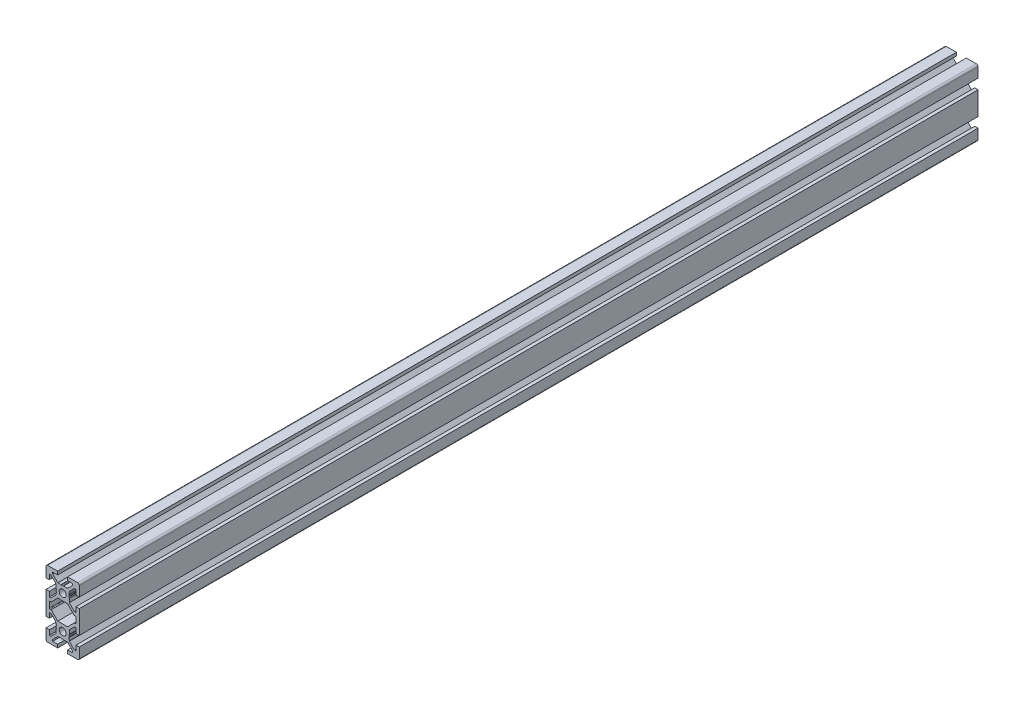
from build123d import *

# Parameters (mm, degrees)
SKETCH1_R           = 2.1
BOSS_EXTRUDE1_DEPTH = 540
SKETCH2_R           = 2
CUT_EXTRUDE1_DEPTH  = 21


with BuildPart() as part:
    # Sketch1 → Boss-Extrude1 (new body)
    with BuildSketch(Plane(origin=(0, 0, -600), x_dir=(-1, 0, 0), z_dir=(0, 0, -1))):
        with BuildLine():
            Line((10, -7), (10, 7))
            Line((10, 7), (8, 7))
            Line((8, 7), (8, 4))
            Line((8, 4), (7.060660172, 4))
            Line((7.060660172, 4), (4, 7.060660172))
            Line((4, 7.060660172), (4, 7.5))
            Line((4, 7.5), (3.750976592, 8.781114371))
            Line((3.750976592, 8.781114371), (3.933012702, 9.096410162))
            ThreePointArc((3.933012702, 9.096410162), (4, 9.346410162), (3.933012702, 9.596410162))
            Line((3.933012702, 9.596410162), (3.7, 10))
            Line((3.7, 10), (3.933012702, 10.403589838))
            ThreePointArc((3.933012702, 10.403589838), (3.982962913, 10.524180316), (4, 10.653589838))
            Line((4, 10.653589838), (4, 12.939339828))
            Line((4, 12.939339828), (7.060660172, 16))
            Line((7.060660172, 16), (8, 16))
            Line((8, 16), (8, 13))
            Line((8, 13), (10, 13))
            Line((10, 13), (10, 19))
            ThreePointArc((10, 19), (9.707106781, 19.707106781), (9, 20))
            Line((9, 20), (3, 20))
            Line((3, 20), (3, 18))
            Line((3, 18), (6, 18))
            Line((6, 18), (6, 17.060660172))
            Line((6, 17.060660172), (2.939339828, 14))
            Line((2.939339828, 14), (2.5, 14))
            Line((2.5, 14), (1.218885629, 13.750976592))
            Line((1.218885629, 13.750976592), (0.903589838, 13.933012702))
            ThreePointArc((0.903589838, 13.933012702), (0.653589838, 14), (0.403589838, 13.933012702))
            Line((0.403589838, 13.933012702), (0, 13.7))
            Line((0, 13.7), (-0.403589838, 13.933012702))
            ThreePointArc((-0.403589838, 13.933012702), (-0.524180316, 13.982962913), (-0.653589838, 14))
            Line((-0.653589838, 14), (-2.939339828, 14))
            Line((-2.939339828, 14), (-6, 17.060660172))
            Line((-6, 17.060660172), (-6, 18))
            Line((-6, 18), (-3, 18))
            Line((-3, 18), (-3, 20))
            Line((-3, 20), (-9, 20))
            ThreePointArc((-9, 20), (-9.707106781, 19.707106781), (-10, 19))
            Line((-10, 19), (-10, 13))
            Line((-10, 13), (-8, 13))
            Line((-8, 13), (-8, 16))
            Line((-8, 16), (-7.060660172, 16))
            Line((-7.060660172, 16), (-4, 12.939339828))
            Line((-4, 12.939339828), (-4, 12.5))
            Line((-4, 12.5), (-3.750976592, 11.218885629))
            Line((-3.750976592, 11.218885629), (-3.933012702, 10.903589838))
            ThreePointArc((-3.933012702, 10.903589838), (-4, 10.653589838), (-3.933012702, 10.403589838))
            Line((-3.933012702, 10.403589838), (-3.7, 10))
            Line((-3.7, 10), (-3.933012702, 9.596410162))
            ThreePointArc((-3.933012702, 9.596410162), (-3.982962913, 9.475819684), (-4, 9.346410162))
            Line((-4, 9.346410162), (-4, 7.060660172))
            Line((-4, 7.060660172), (-7.060660172, 4))
            Line((-7.060660172, 4), (-8, 4))
            Line((-8, 4), (-8, 7))
            Line((-8, 7), (-10, 7))
            Line((-10, 7), (-10, -7))
            Line((-10, -7), (-8, -7))
            Line((-8, -7), (-8, -4))
            Line((-8, -4), (-7.060660172, -4))
            Line((-7.060660172, -4), (-4, -7.060660172))
            Line((-4, -7.060660172), (-4, -9.346410162))
            ThreePointArc((-4, -9.346410162), (-3.982962913, -9.475819684), (-3.933012702, -9.596410162))
            Line((-3.933012702, -9.596410162), (-3.7, -10))
            Line((-3.7, -10), (-3.933012702, -10.403589838))
            ThreePointArc((-3.933012702, -10.403589838), (-4, -10.653589838), (-3.933012702, -10.903589838))
            Line((-3.933012702, -10.903589838), (-3.750976592, -11.218885629))
            Line((-3.750976592, -11.218885629), (-4, -12.5))
            Line((-4, -12.5), (-4, -12.939339828))
            Line((-4, -12.939339828), (-7.060660172, -16))
            Line((-7.060660172, -16), (-8, -16))
            Line((-8, -16), (-8, -13))
            Line((-8, -13), (-10, -13))
            Line((-10, -13), (-10, -19))
            ThreePointArc((-10, -19), (-9.707106781, -19.707106781), (-9, -20))
            Line((-9, -20), (-3, -20))
            Line((-3, -20), (-3, -18))
            Line((-3, -18), (-6, -18))
            Line((-6, -18), (-6, -17.060660172))
            Line((-6, -17.060660172), (-2.939339828, -14))
            Line((-2.939339828, -14), (-0.653589838, -14))
            ThreePointArc((-0.653589838, -14), (-0.524180316, -13.982962913), (-0.403589838, -13.933012702))
            Line((-0.403589838, -13.933012702), (0, -13.7))
            Line((0, -13.7), (0.403589839, -13.933012702))
            ThreePointArc((0.403589839, -13.933012702), (0.653589839, -14), (0.903589838, -13.933012702))
            Line((0.903589838, -13.933012702), (1.218885629, -13.750976592))
            Line((1.218885629, -13.750976592), (2.5, -14))
            Line((2.5, -14), (2.939339828, -14))
            Line((2.939339828, -14), (6, -17.060660172))
            Line((6, -17.060660172), (6, -18))
            Line((6, -18), (3, -18))
            Line((3, -18), (3, -20))
            Line((3, -20), (9, -20))
            ThreePointArc((9, -20), (9.707106781, -19.707106781), (10, -19))
            Line((10, -19), (10, -13))
            Line((10, -13), (8, -13))
            Line((8, -13), (8, -16))
            Line((8, -16), (7.060660172, -16))
            Line((7.060660172, -16), (4, -12.939339828))
            Line((4, -12.939339828), (4, -10.653589838))
            ThreePointArc((4, -10.653589838), (3.982962913, -10.524180316), (3.933012702, -10.403589838))
            Line((3.933012702, -10.403589838), (3.7, -10))
            Line((3.7, -10), (3.933012702, -9.596410162))
            ThreePointArc((3.933012702, -9.596410162), (4, -9.346410162), (3.933012702, -9.096410162))
            Line((3.933012702, -9.096410162), (3.750976592, -8.781114371))
            Line((3.750976592, -8.781114371), (4, -7.5))
            Line((4, -7.5), (4, -7.060660172))
            Line((4, -7.060660172), (7.060660172, -4))
            Line((7.060660172, -4), (8, -4))
            Line((8, -4), (8, -7))
            Line((8, -7), (10, -7))
        make_face()
        with Locations((0, -10)):
            Circle(SKETCH1_R, mode=Mode.SUBTRACT)
        with Locations((0, 10)):
            Circle(SKETCH1_R, mode=Mode.SUBTRACT)
        with BuildLine():
            Line((8, 1.7), (8, -1.7))
            ThreePointArc((8, -1.7), (7.912132034, -1.912132034), (7.7, -2))
            Line((7.7, -2), (7.063603897, -2))
            ThreePointArc((7.063603897, -2), (6.948798867, -2.02283614), (6.851471863, -2.087867966))
            Line((6.851471863, -2.087867966), (2.939339828, -6))
            Line((2.939339828, -6), (-2.939339828, -6))
            Line((-2.939339828, -6), (-6.851471863, -2.087867966))
            ThreePointArc((-6.851471863, -2.087867966), (-6.948798867, -2.02283614), (-7.063603897, -2))
            Line((-7.063603897, -2), (-7.7, -2))
            ThreePointArc((-7.7, -2), (-7.912132034, -1.912132034), (-8, -1.7))
            Line((-8, -1.7), (-8, 1.7))
            ThreePointArc((-8, 1.7), (-7.912132034, 1.912132034), (-7.7, 2))
            Line((-7.7, 2), (-7.063603897, 2))
            ThreePointArc((-7.063603897, 2), (-6.948798867, 2.02283614), (-6.851471863, 2.087867966))
            Line((-6.851471863, 2.087867966), (-2.939339828, 6))
            Line((-2.939339828, 6), (2.939339828, 6))
            Line((2.939339828, 6), (6.851471863, 2.087867966))
            ThreePointArc((6.851471863, 2.087867966), (6.948798867, 2.02283614), (7.063603897, 2))
            Line((7.063603897, 2), (7.7, 2))
            ThreePointArc((7.7, 2), (7.912132034, 1.912132034), (8, 1.7))
        make_face(mode=Mode.SUBTRACT)
    extrude(amount=-BOSS_EXTRUDE1_DEPTH)

    # Sketch2 → Cut-Extrude1 (cut, through all)
    with BuildSketch(Plane(origin=(10, 0, 0), x_dir=(0, 0, -1), z_dir=(1, 0, 0))):
        with Locations((70, 10)):
            Circle(SKETCH2_R)
        with Locations((70, -10)):
            Circle(SKETCH2_R)
    cut_extrude1 = extrude(amount=-CUT_EXTRUDE1_DEPTH, mode=Mode.SUBTRACT)

    # Mirror1: Cut-Extrude1 across plane
    add(cut_extrude1.mirror(Plane.XY.offset(-330)), mode=Mode.SUBTRACT)


solid = part.part
